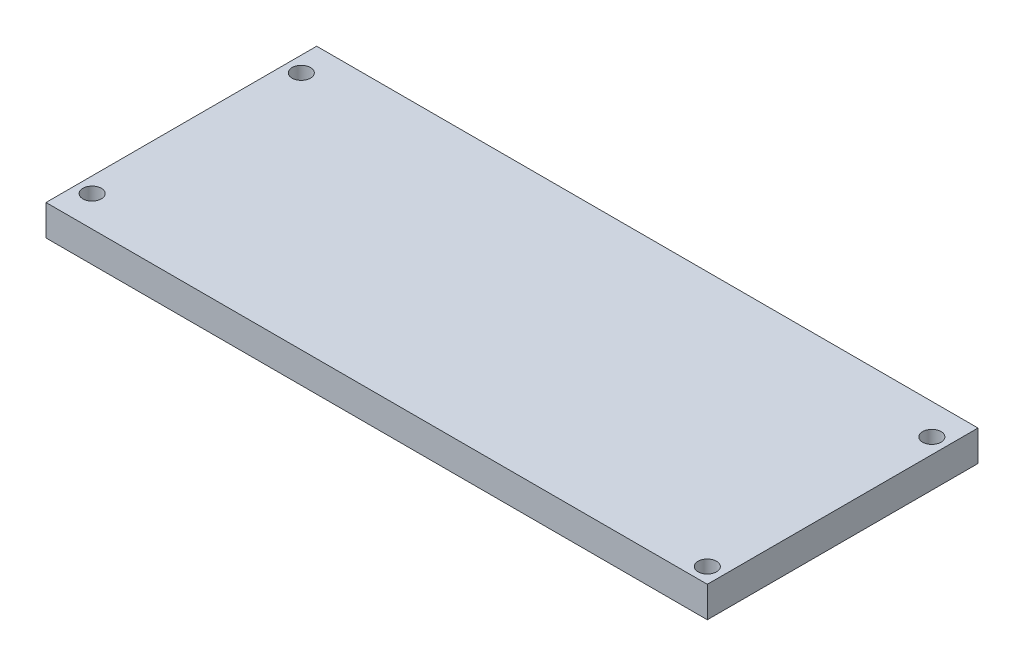
from build123d import *

# Parameters (mm, degrees)
SKETCH1_W           = 215
SKETCH1_H           = 88
SKETCH1_R           = 3
BOSS_EXTRUDE1_DEPTH = 10


with BuildPart() as part:
    # Sketch1 → Boss-Extrude1 (new body)
    with BuildSketch(Plane(origin=(0, 0, 0), x_dir=(1, 0, 0), z_dir=(0, 1, 0))):
        with Locations((107.5, 44)):
            Rectangle(SKETCH1_W, SKETCH1_H)
        with Locations((5, 78)):
            Circle(SKETCH1_R, mode=Mode.SUBTRACT)
        with Locations((5, 10)):
            Circle(SKETCH1_R, mode=Mode.SUBTRACT)
        with Locations((210, 78)):
            Circle(SKETCH1_R, mode=Mode.SUBTRACT)
        with Locations((210, 5)):
            Circle(SKETCH1_R, mode=Mode.SUBTRACT)
    extrude(amount=BOSS_EXTRUDE1_DEPTH)


solid = part.part
